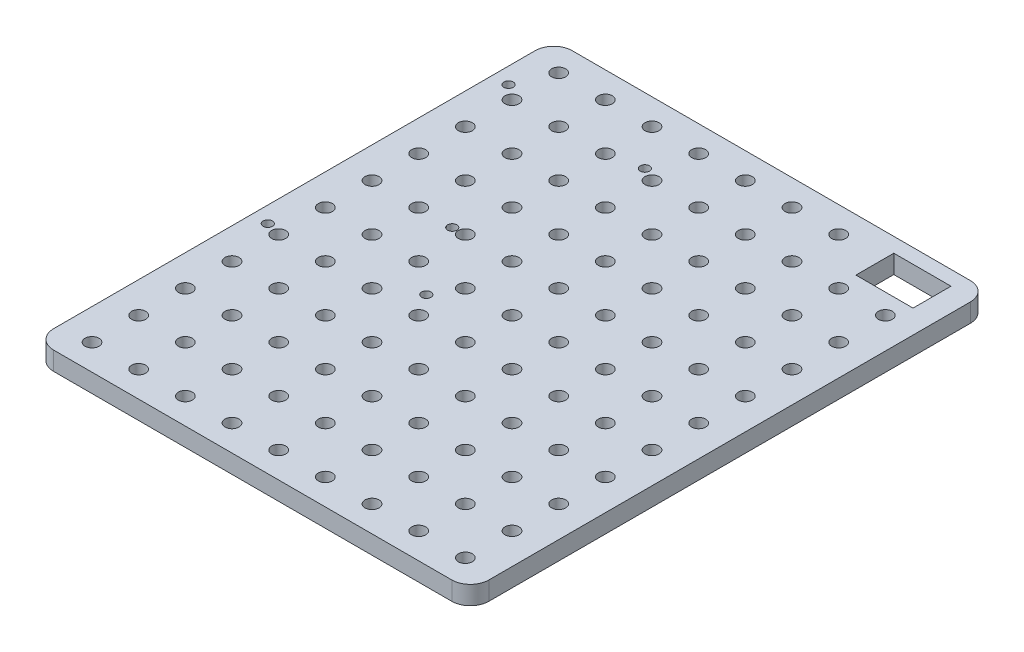
from build123d import *

# Parameters (mm, degrees)
SKETCH2_W            = 149.225
SKETCH2_H            = 177.8
BOSS_EXTRUDE1_DEPTH  = 6.35
FILLET1_R            = 6.35
SKETCH3_R            = 2.4
CUT_EXTRUDE2_DEPTH   = 7.35
LPATTERN2_COUNT      = 9
LPATTERN2_PITCH      = 16
LPATTERN2_COUNT_DIR2 = 11
LPATTERN2_PITCH_DIR2 = 16
SKETCH4_R            = 1.6
MOUNTING_HOLES_DEPTH = 7.35
SKETCH5_W            = 19.6
SKETCH5_H            = 13
SWITCH_CUTOUT_DEPTH  = 7.35


with BuildPart() as part:
    # Sketch2 → Boss-Extrude1 (new body)
    with BuildSketch(Plane(origin=(0, 0, 0), x_dir=(1, 0, 0), z_dir=(0, 1, 0))):
        Rectangle(SKETCH2_W, SKETCH2_H)
    extrude(amount=BOSS_EXTRUDE1_DEPTH)

    # Fillet1
    fillet1_edges = [part.edges().sort_by_distance(p)[0] for p in [
        (74.6125, 3.175, 88.9),
        (-74.6125, 3.175, 88.9),
        (-74.6125, 3.175, -88.9),
        (74.6125, 3.175, -88.9),
    ]]
    fillet(fillet1_edges, radius=FILLET1_R)

    # Sketch3 → Cut-Extrude2 (cut, through all)
    with BuildSketch(Plane(origin=(0, 6.35, 0), x_dir=(1, 0, 0), z_dir=(0, 1, 0))):
        with Locations((-64, 80)):
            Circle(SKETCH3_R)
    cut_extrude2 = extrude(amount=-CUT_EXTRUDE2_DEPTH, mode=Mode.SUBTRACT)

    # LPattern2: Cut-Extrude2 9 × 11, 2 skipped
    with Locations(*[(i * LPATTERN2_PITCH, 0, j * LPATTERN2_PITCH_DIR2) for i in range(LPATTERN2_COUNT) for j in range(LPATTERN2_COUNT_DIR2) if (i, j) not in ((0, 0), (7, 0), (8, 0))]):
        add(cut_extrude2, mode=Mode.SUBTRACT)

    # Sketch4 → MOUNTING_HOLES (cut, through all)
    with BuildSketch(Plane(origin=(0, 6.35, 0), x_dir=(1, 0, 0), z_dir=(0, 1, 0))):
        with Locations((-69.08, 67.9)):
            Circle(SKETCH4_R)
        with Locations((-20.82, 66.376)):
            Circle(SKETCH4_R)
        with Locations((-20.82, -8.554)):
            Circle(SKETCH4_R)
        with Locations((-69.08, -14.65)):
            Circle(SKETCH4_R)
        with Locations((-64, 15.83)):
            Circle(SKETCH4_R)
        with Locations((-36.314, 15.83)):
            Circle(SKETCH4_R)
    extrude(amount=-MOUNTING_HOLES_DEPTH, mode=Mode.SUBTRACT)

    # Sketch5 → SWITCH_CUTOUT (cut, through all)
    with BuildSketch(Plane(origin=(0, 6.35, 0), x_dir=(1, 0, 0), z_dir=(0, 1, 0))):
        with Locations((56.8125, 77.4)):
            Rectangle(SKETCH5_W, SKETCH5_H)
    extrude(amount=-SWITCH_CUTOUT_DEPTH, mode=Mode.SUBTRACT)


solid = part.part
